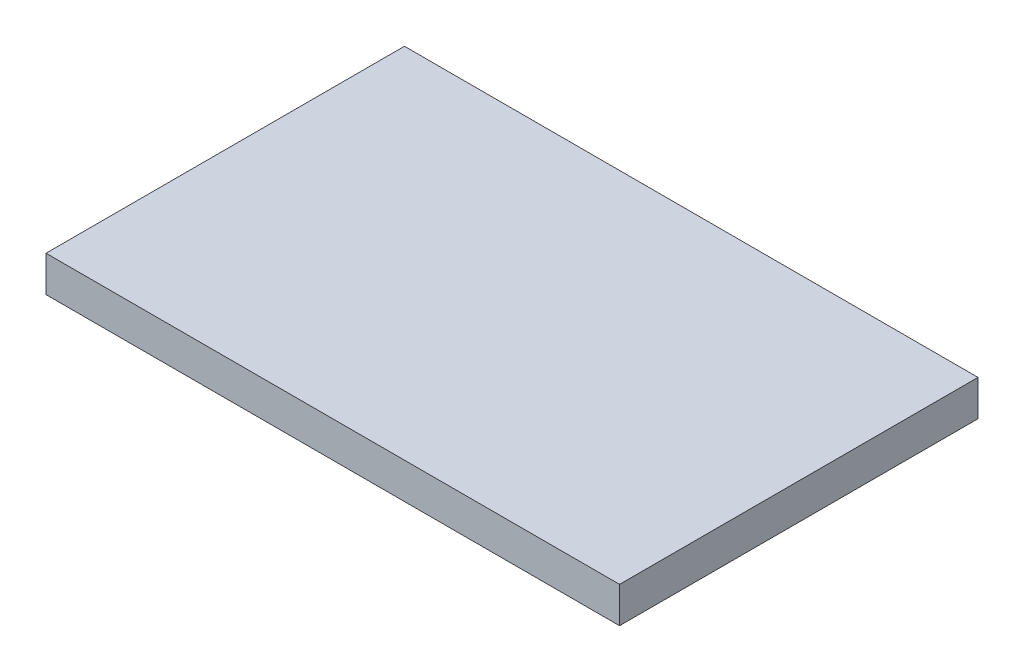
from build123d import *

# Parameters (mm, degrees)
SKETCH1_W           = 203.2
SKETCH1_H           = 12.7
BOSS_EXTRUDE1_DEPTH = 127


with BuildPart() as part:
    # Sketch1 → Boss-Extrude1 (new body)
    with BuildSketch(Plane.XY):
        with Locations((101.6, -6.35)):
            Rectangle(SKETCH1_W, SKETCH1_H)
    extrude(amount=BOSS_EXTRUDE1_DEPTH)


solid = part.part
